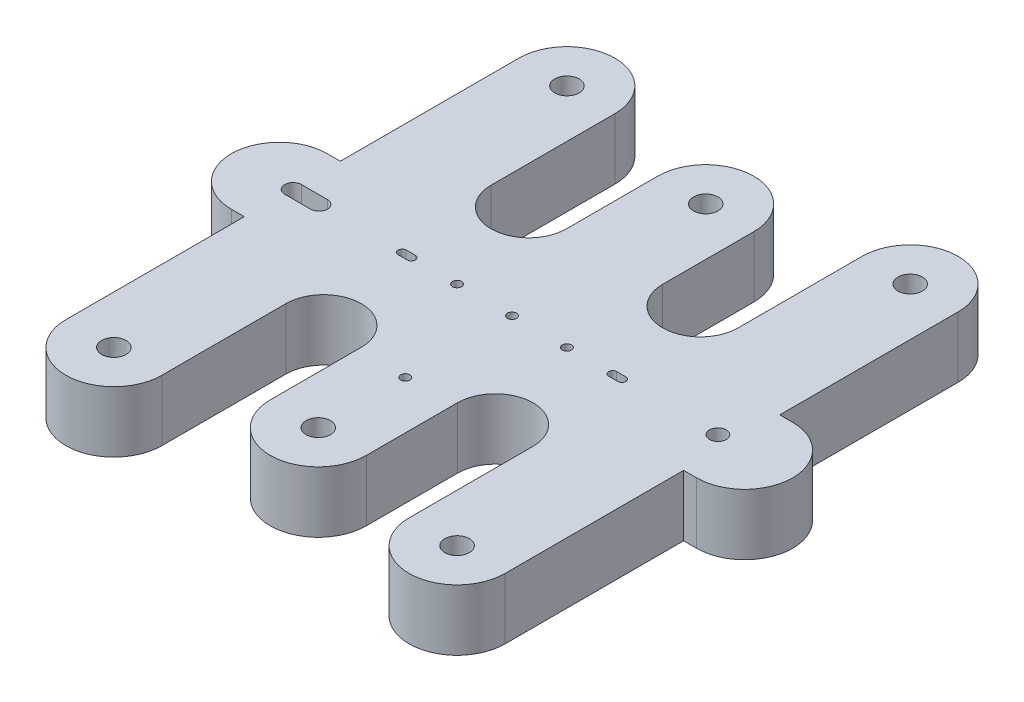
from build123d import *

# Parameters (mm, degrees)
SKETCH1_R       = 0.8
EXTRUDE9_DEPTH  = 4
SKETCH2_R       = 0.55
EXTRUDE10_DEPTH = 5
SKETCH3_R       = 0.3
EXTRUDE11_DEPTH = 10


with BuildPart() as part:
    # Sketch1 → Extrude9 (new body)
    with BuildSketch(Plane(origin=(0, 0, 0), x_dir=(1, 0, 0), z_dir=(0, 1, 0))):
        with BuildLine():
            Line((-14.4, 14.85), (-14.4, 3.15))
            Line((-14.4, 3.15), (-15.25, 3.15))
            ThreePointArc((-15.25, 3.15), (-18.4, 0), (-15.25, -3.15))
            Line((-15.25, -3.15), (-14.4, -3.15))
            Line((-14.4, -3.15), (-14.4, -14.85))
            ThreePointArc((-14.4, -14.85), (-11.25, -18), (-8.1, -14.85))
            Line((-8.1, -14.85), (-8.1, -6.725))
            ThreePointArc((-8.1, -6.725), (-5.625, -4.25), (-3.15, -6.725))
            Line((-3.15, -6.725), (-3.15, -12.7))
            ThreePointArc((-3.15, -12.7), (0, -15.85), (3.15, -12.7))
            Line((3.15, -12.7), (3.15, -6.725))
            ThreePointArc((3.15, -6.725), (5.625, -4.25), (8.1, -6.725))
            Line((8.1, -6.725), (8.1, -14.85))
            ThreePointArc((8.1, -14.85), (11.25, -18), (14.4, -14.85))
            Line((14.4, -14.85), (14.4, -3.15))
            Line((14.4, -3.15), (15.25, -3.15))
            ThreePointArc((15.25, -3.15), (18.4, 0), (15.25, 3.15))
            Line((15.25, 3.15), (14.4, 3.15))
            Line((14.4, 3.15), (14.4, 14.85))
            ThreePointArc((14.4, 14.85), (11.25, 18), (8.1, 14.85))
            Line((8.1, 14.85), (8.1, 6.725))
            ThreePointArc((8.1, 6.725), (5.625, 4.25), (3.15, 6.725))
            Line((3.15, 6.725), (3.15, 12.7))
            ThreePointArc((3.15, 12.7), (0, 15.85), (-3.15, 12.7))
            Line((-3.15, 12.7), (-3.15, 6.725))
            ThreePointArc((-3.15, 6.725), (-5.625, 4.25), (-8.1, 6.725))
            Line((-8.1, 6.725), (-8.1, 14.85))
            ThreePointArc((-8.1, 14.85), (-11.25, 18), (-14.4, 14.85))
        make_face()
        with Locations((-11.25, 14.85)):
            Circle(SKETCH1_R, mode=Mode.SUBTRACT)
        with Locations((0, 12.7)):
            Circle(SKETCH1_R, mode=Mode.SUBTRACT)
        with Locations((11.25, 14.85)):
            Circle(SKETCH1_R, mode=Mode.SUBTRACT)
        with Locations((11.25, -14.85)):
            Circle(SKETCH1_R, mode=Mode.SUBTRACT)
        with Locations((0, -12.7)):
            Circle(SKETCH1_R, mode=Mode.SUBTRACT)
        with Locations((-11.25, -14.85)):
            Circle(SKETCH1_R, mode=Mode.SUBTRACT)
    extrude(amount=EXTRUDE9_DEPTH)

    # Sketch2 → Extrude10 (cut, through all)
    with BuildSketch(Plane(origin=(0, 0, 0), x_dir=(1, 0, 0), z_dir=(0, 1, 0))):
        with Locations((13.5, 0)):
            Circle(SKETCH2_R)
        with BuildLine():
            Line((-14.35, 0.55), (-12.65, 0.55))
            ThreePointArc((-12.65, 0.55), (-12.1, 0), (-12.65, -0.55))
            Line((-12.65, -0.55), (-14.35, -0.55))
            ThreePointArc((-14.35, -0.55), (-14.9, 0), (-14.35, 0.55))
        make_face()
    extrude(amount=EXTRUDE10_DEPTH, mode=Mode.SUBTRACT)

    # Sketch3 → Extrude11 (cut)
    with BuildSketch(Plane(origin=(0, 0, 0), x_dir=(1, 0, 0), z_dir=(0, 1, 0))):
        with Locations((-3.6, 0)):
            Circle(SKETCH3_R)
        with Locations((3.6, 0)):
            Circle(SKETCH3_R)
        Circle(SKETCH3_R)
        with Locations((0, -7)):
            Circle(SKETCH3_R)
        with BuildLine():
            Line((-7.2, 0.264383356), (-6.6, 0.264383356))
            ThreePointArc((-6.6, 0.264383356), (-6.335616644, 0), (-6.6, -0.264383356))
            Line((-6.6, -0.264383356), (-7.2, -0.264383356))
            ThreePointArc((-7.2, -0.264383356), (-7.464383356, 0), (-7.2, 0.264383356))
        make_face()
        with BuildLine():
            Line((6.6, 0.264383356), (7.2, 0.264383356))
            ThreePointArc((7.2, 0.264383356), (7.464383356, 0), (7.2, -0.264383356))
            Line((7.2, -0.264383356), (6.6, -0.264383356))
            ThreePointArc((6.6, -0.264383356), (6.335616644, 0), (6.6, 0.264383356))
        make_face()
    extrude(amount=EXTRUDE11_DEPTH, mode=Mode.SUBTRACT)


solid = part.part
